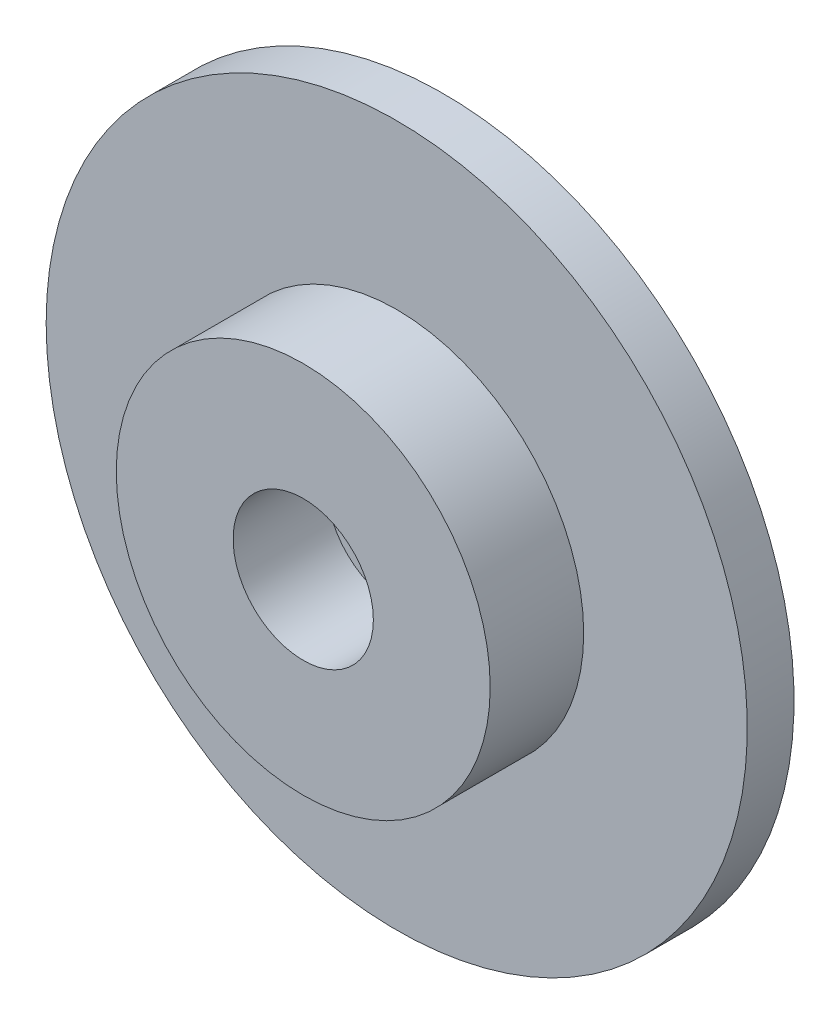
from build123d import *

# Parameters (mm, degrees)
ESQUISSE1_R             = 4
BOSS_EXTRU_1_DEPTH      = 2
ESQUISSE2_R             = 1.5
ENL_V_MAT_EXTRU_1_DEPTH = 2.5
ESQUISSE3_R             = 7.5
BOSS_EXTRU_2_DEPTH      = 1


with BuildPart() as part:
    # Esquisse1 → Boss.-Extru.1 (new body)
    with BuildSketch(Plane.XY):
        Circle(ESQUISSE1_R)
    extrude(amount=BOSS_EXTRU_1_DEPTH)

    # Esquisse2 → Enlèv. mat.-Extru.1 (cut)
    with BuildSketch(Plane.XY.offset(2)):
        Circle(ESQUISSE2_R)
    extrude(amount=-ENL_V_MAT_EXTRU_1_DEPTH, mode=Mode.SUBTRACT)

    # Esquisse3 → Boss.-Extru.2 (add)
    with BuildSketch(Plane(origin=(0, 0, 0), x_dir=(-1, 0, 0), z_dir=(0, 0, -1))):
        Circle(ESQUISSE3_R)
    extrude(amount=BOSS_EXTRU_2_DEPTH)


solid = part.part
